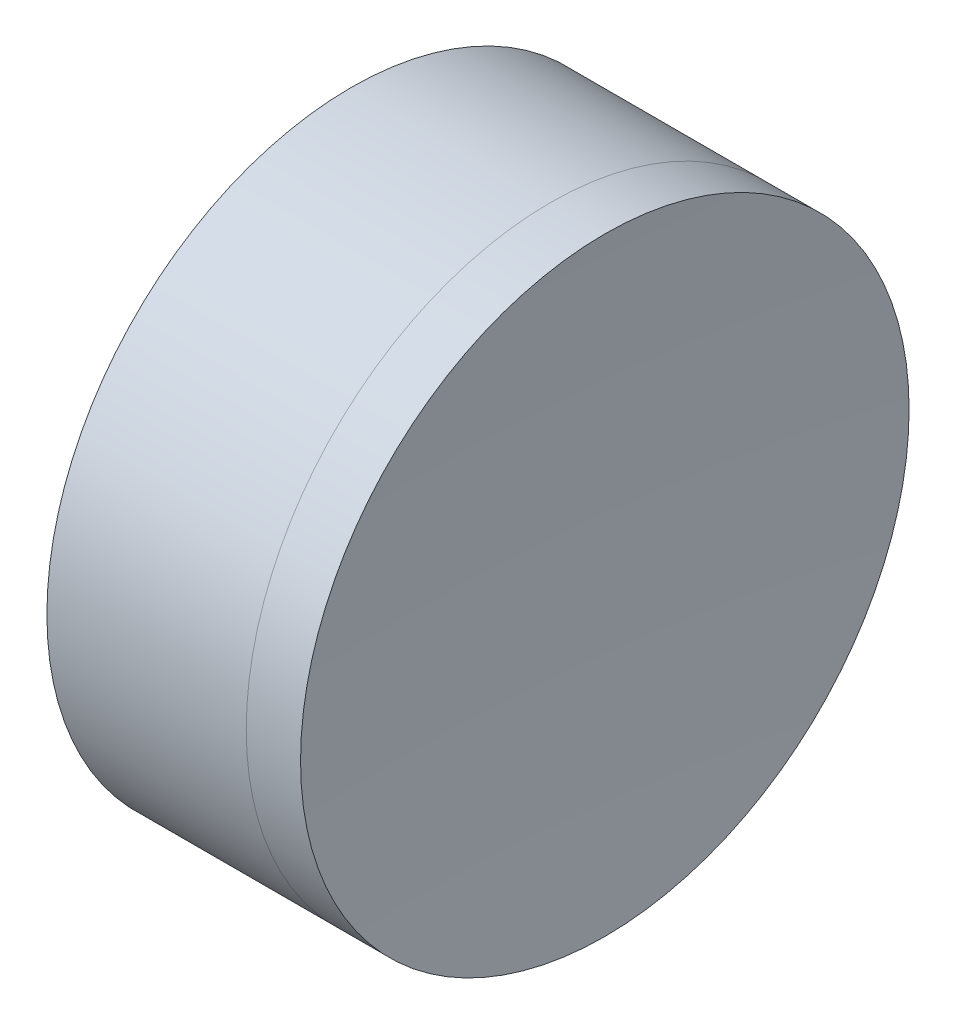
from build123d import *


with BuildPart() as part:
    # 草图1 one side → 旋转1 (revolve)
    with BuildSketch(Plane(origin=(0, 0, 0), x_dir=(1, 0, 0), z_dir=(0, 1, 0)), mode=Mode.PRIVATE) as revolve_1_sk:
        with BuildLine():
            Line((265.443466943, 12.7), (257.123316567, 12.7))
            ThreePointArc((257.123316567, 12.7), (259.481509201, 6.543624286), (260.283391755, 0))
            Line((260.283391755, 0), (262.283391755, 0))
            ThreePointArc((262.283391755, 0), (263.085274309, 6.543624286), (265.443466943, 12.7))
        make_face()
    revolve(revolve_1_sk.sketch.rotate(Axis((-0.816062176, 0, 0), (1, 0, 0)), 180), axis=Axis((-0.816062176, 0, 0), (1, 0, 0)))  # turned: the seam where the file's is


with BuildPart() as body_2:
    # 草图2 one side → 旋转3 (revolve)
    with BuildSketch(Plane(origin=(0, 0, 0), x_dir=(1, 0, 0), z_dir=(0, 1, 0)), mode=Mode.PRIVATE) as revolve_3_sk:
        with BuildLine():
            Line((267.710115045, 12.7), (265.443466943, 12.7))
            ThreePointArc((265.443466943, 12.7), (263.085274309, 6.543624286), (262.283391755, 0))
            Line((262.283391755, 0), (267.283391755, 0))
            ThreePointArc((267.283391755, 0), (267.390102671, 6.353583492), (267.710115045, 12.7))
        make_face()
    revolve(revolve_3_sk.sketch.rotate(Axis((257.123316567, 0, 0), (1, 0, 0)), 180), axis=Axis((257.123316567, 0, 0), (1, 0, 0)))  # turned: the seam where the file's is


solid = Compound([part.part, body_2.part])
